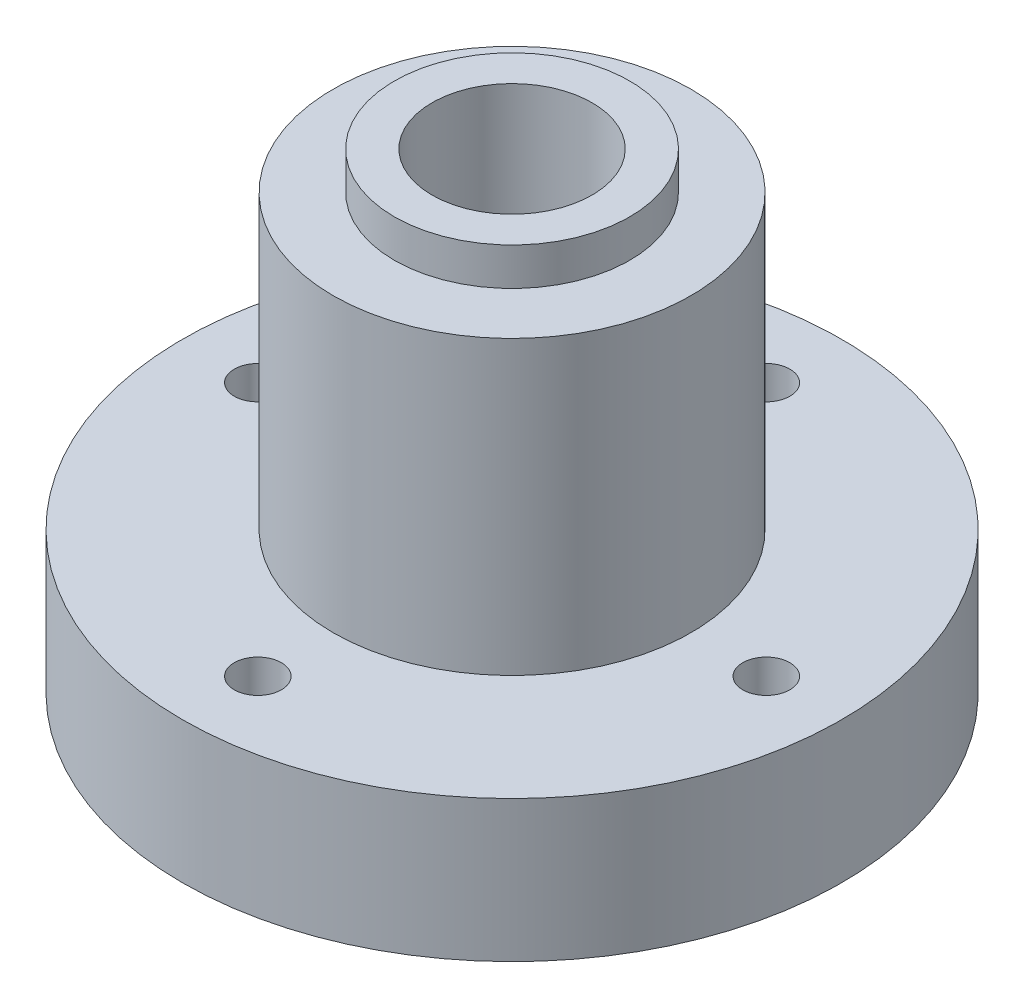
from build123d import *

# Parameters (mm, degrees)
M6_TAPPED_HOLE1_D  = 5
SKETCH4_R          = 16
CUT_EXTRUDE1_DEPTH = 9


with BuildPart() as part:
    # Sketch1 → Revolve1 (revolve)
    with BuildSketch(Plane.XY):
        Polygon((-8.5, 0), (-35, 0), (-35, 15), (-19, 15), (-19, 46), (-12.5, 46), (-12.5, 50), (-8.5, 50), align=None)
    revolve(axis=Axis((0, 0, 0), (0, -1, 0)))

    # M6 Tapped Hole1 (through all)
    with Locations(Plane(origin=(0, 15, 0), x_dir=(1, 0, 0), z_dir=(0, 1, 0))):
        with Locations((-27, 0), (0, 27), (27, 0), (0, -27)):
            Hole(M6_TAPPED_HOLE1_D / 2)

    # Sketch4 → Cut-Extrude1 (cut)
    with BuildSketch(Plane.XZ):
        Circle(SKETCH4_R)
    extrude(amount=-CUT_EXTRUDE1_DEPTH, mode=Mode.SUBTRACT)


solid = part.part
